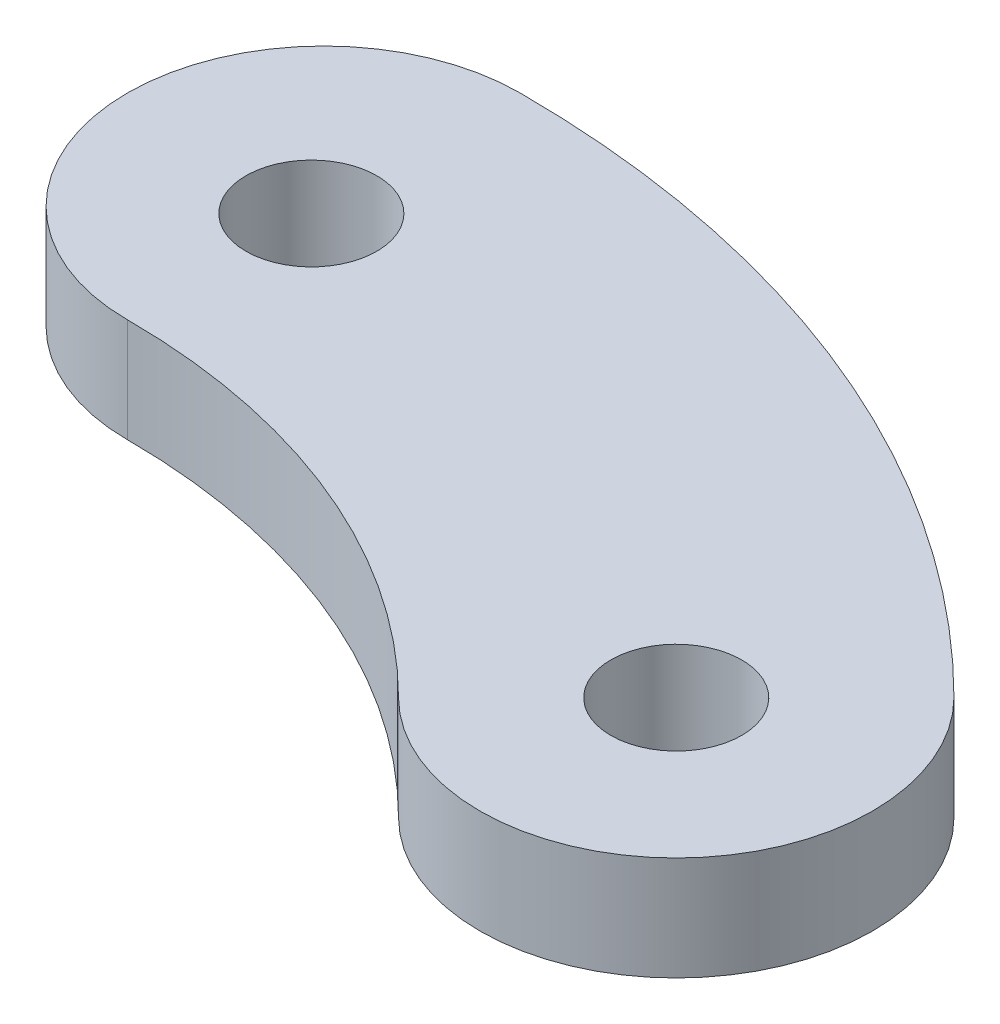
from build123d import *

# Parameters (mm, degrees)
SKETCH1_R           = 5
BOSS_EXTRUDE1_DEPTH = 7.9375


with BuildPart() as part:
    # Sketch1 → Boss-Extrude1 (new body)
    with BuildSketch(Plane(origin=(0, 0, 0), x_dir=(1, 0, 0), z_dir=(0, 1, 0))):
        with BuildLine():
            ThreePointArc((56.568542495, 56.568542495), (30.614674589, 73.910362601), (0, 80))
            ThreePointArc((0, 80), (-15, 65), (0, 50))
            ThreePointArc((0, 50), (19.134171618, 46.193976626), (35.355339059, 35.355339059))
            ThreePointArc((35.355339059, 35.355339059), (56.568542495, 35.355339059), (56.568542495, 56.568542495))
        make_face()
        with Locations((0, 64.05375952)):
            Circle(SKETCH1_R, mode=Mode.SUBTRACT)
        with Locations((45.961940777, 45.961940777)):
            Circle(SKETCH1_R, mode=Mode.SUBTRACT)
    extrude(amount=BOSS_EXTRUDE1_DEPTH)


solid = part.part
